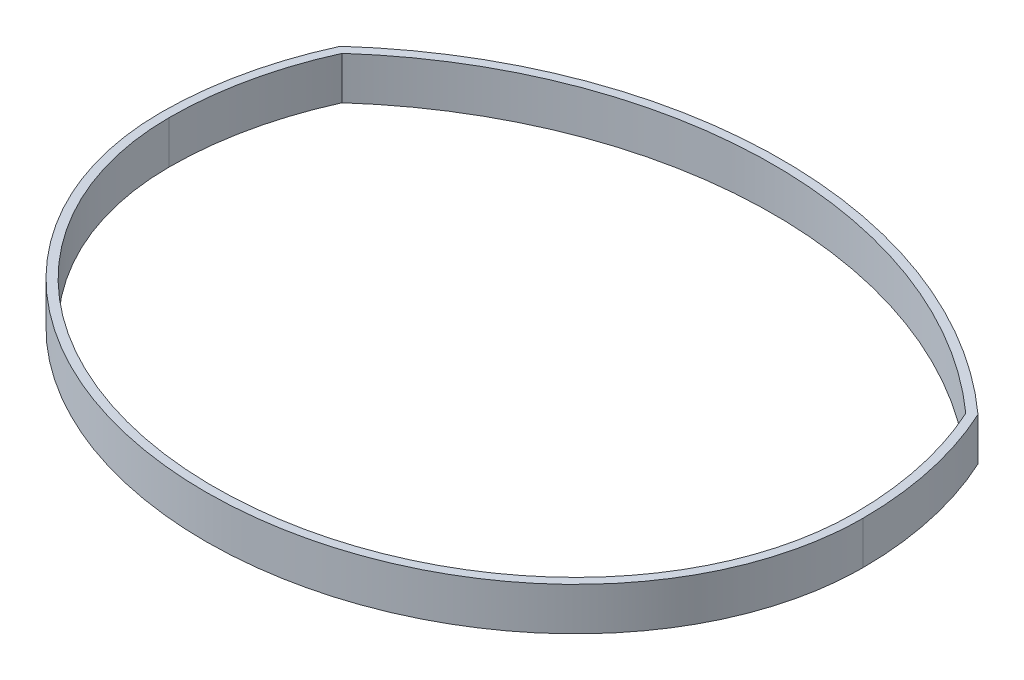
from build123d import *

# Parameters (mm, degrees)
BOSS_EXTRUDE1_DEPTH = 12.7


with BuildPart() as part:
    # Sketch1 → Boss-Extrude1 (new body)
    with BuildSketch(Plane(origin=(0, 0, 0), x_dir=(1, 0, 0), z_dir=(0, 1, 0))):
        with BuildLine():
            ThreePointArc((94.540146528, 43.672649272), (0, 80.034125107), (-94.540146528, 43.672649272))
            ThreePointArc((-94.540146528, 43.672649272), (-101.711726117, 22.357646796), (-104.14, 0))
            add(Edge.make_bspline(
                [(-104.14, 0), (-104.14, -11.915016239), (-98.667803671, -35.777492174), (-75.403845015, -65.961664527), (-40.759055226, -86.041153574), (0, -93.073629784), (40.759055226, -86.041153574), (75.403845015, -65.961664527), (98.667803671, -35.777492174), (104.14, -11.915016239), (104.14, 0)],
                knots=[0, 0, 0, 0, 0.392699082, 0.785398163, 1.178097245, 1.570796327, 1.963495408, 2.35619449, 2.748893572, 3.141592654, 3.141592654, 3.141592654, 3.141592654], degree=3))
            ThreePointArc((104.14, 0), (101.711726117, 22.357646796), (94.540146528, 43.672649272))
        make_face()
        with BuildLine():
            ThreePointArc((-92.45080744, 42.135593074), (-99.28635867, 21.558733312), (-101.6, 0))
            add(Edge.make_bspline(
                [(-101.6, 0), (-101.6, -88.189471047), (0, -88.189471047), (101.6, -88.189471047), (101.6, 0)],
                knots=[0, 0, 0, 1.570796327, 1.570796327, 3.141592654, 3.141592654, 3.141592654], degree=2, weights=[1, 0.707106781, 1, 0.707106781, 1]))
            ThreePointArc((101.6, 0), (99.28635867, 21.558733312), (92.45080744, 42.135593074))
            ThreePointArc((92.45080744, 42.135593074), (0, 77.494125107), (-92.45080744, 42.135593074))
        make_face(mode=Mode.SUBTRACT)
    extrude(amount=BOSS_EXTRUDE1_DEPTH)


solid = part.part
